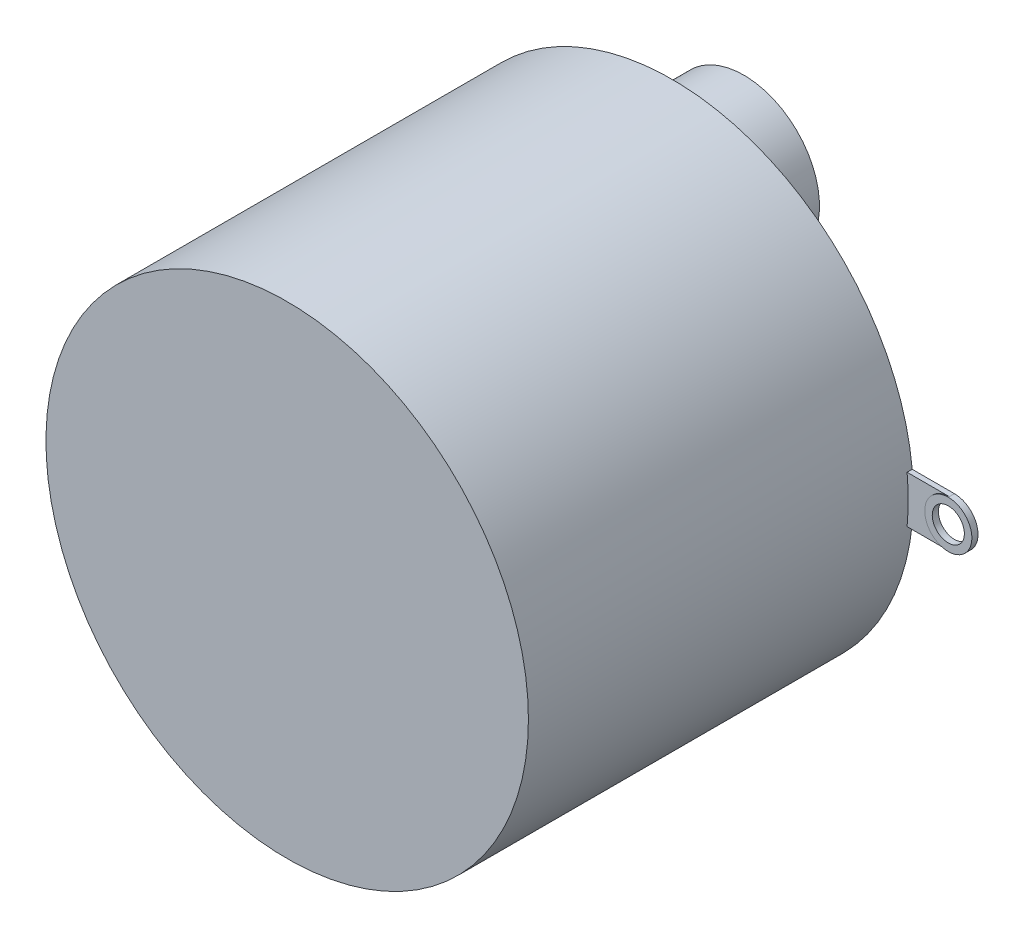
from build123d import *

# Parameters (mm, degrees)
SKETCH1_R             = 11.938
BOSS_EXTRUDE1_DEPTH   = 19.05
SKETCH2_R             = 1.177518958
BOSS_EXTRUDE2_DEPTH   = 0.304204724
SKETCH2_R_2           = 1.16518976
BOSS_EXTRUDE2_2_DEPTH = 0.304204724
SKETCH3_W             = 28.109952108
SKETCH3_H             = 2.33037952
BOSS_EXTRUDE3_DEPTH   = 0.254
SKETCH4_R             = 0.795236377
CUT_EXTRUDE1_DEPTH    = 0.905720074
SKETCH5_R             = 0.753950063
CUT_EXTRUDE2_DEPTH    = 1.016
SKETCH6_R             = 0.47077468
BOSS_EXTRUDE4_DEPTH   = 0.245031324
SKETCH8_R             = 3.743161578
BOSS_EXTRUDE5_DEPTH   = 3.302


with BuildPart() as part:
    # Sketch1 → Boss-Extrude1 (new body)
    with BuildSketch(Plane.XY):
        Circle(SKETCH1_R)
    extrude(amount=BOSS_EXTRUDE1_DEPTH)



with BuildPart() as body_2:
    # Sketch2 → Boss-Extrude2 (new body)
    with BuildSketch(Plane(origin=(0, 0, 0), x_dir=(-1, 0, 0), z_dir=(0, 0, -1))):
        with Locations((13.97, 0)):
            Circle(SKETCH2_R)
    extrude(amount=-BOSS_EXTRUDE2_DEPTH)


with BuildPart() as body_3:
    # Sketch2 → Boss-Extrude2 2 (new body)
    with BuildSketch(Plane(origin=(0, 0, 0), x_dir=(-1, 0, 0), z_dir=(0, 0, -1))):
        with Locations((-13.97, 0)):
            Circle(SKETCH2_R_2)
    extrude(amount=-BOSS_EXTRUDE2_2_DEPTH)


with BuildPart() as part_1:
    add(part.part)

    add(body_2.part)  # Boss-Extrude3 merges body 2

    add(body_3.part)  # Boss-Extrude3 merges body 3
    # Sketch3 → Boss-Extrude3 (add)
    with BuildSketch(Plane(origin=(0, 0, 0), x_dir=(-1, 0, 0), z_dir=(0, 0, -1))):
        with Locations((0.084976054, 0)):
            Rectangle(SKETCH3_W, SKETCH3_H)
    extrude(amount=-BOSS_EXTRUDE3_DEPTH)

    # Sketch4 → Cut-Extrude1 (cut)
    with BuildSketch(Plane(origin=(0, 0, 0), x_dir=(-1, 0, 0), z_dir=(0, 0, -1))):
        with Locations((-13.97, 0)):
            Circle(SKETCH4_R)
    extrude(amount=-CUT_EXTRUDE1_DEPTH, mode=Mode.SUBTRACT)

    # Sketch5 → Cut-Extrude2 (cut)
    with BuildSketch(Plane(origin=(0, 0, 0), x_dir=(-1, 0, 0), z_dir=(0, 0, -1))):
        with Locations((13.97, 0)):
            Circle(SKETCH5_R)
    extrude(amount=-CUT_EXTRUDE2_DEPTH, mode=Mode.SUBTRACT)

    # Sketch6 → Boss-Extrude4 (add)
    with BuildSketch(Plane(origin=(0, 0, 0), x_dir=(-1, 0, 0), z_dir=(0, 0, -1))):
        with Locations((0, 6.604)):
            Circle(SKETCH6_R)
    extrude(amount=BOSS_EXTRUDE4_DEPTH)

    # Sketch8 → Boss-Extrude5 (add)
    with BuildSketch(Plane(origin=(0, 0, -0.245031324), x_dir=(-1, 0, 0), z_dir=(0, 0, -1))):
        with Locations((0, 6.604)):
            Circle(SKETCH8_R)
    extrude(amount=BOSS_EXTRUDE5_DEPTH)


solid = part_1.part
